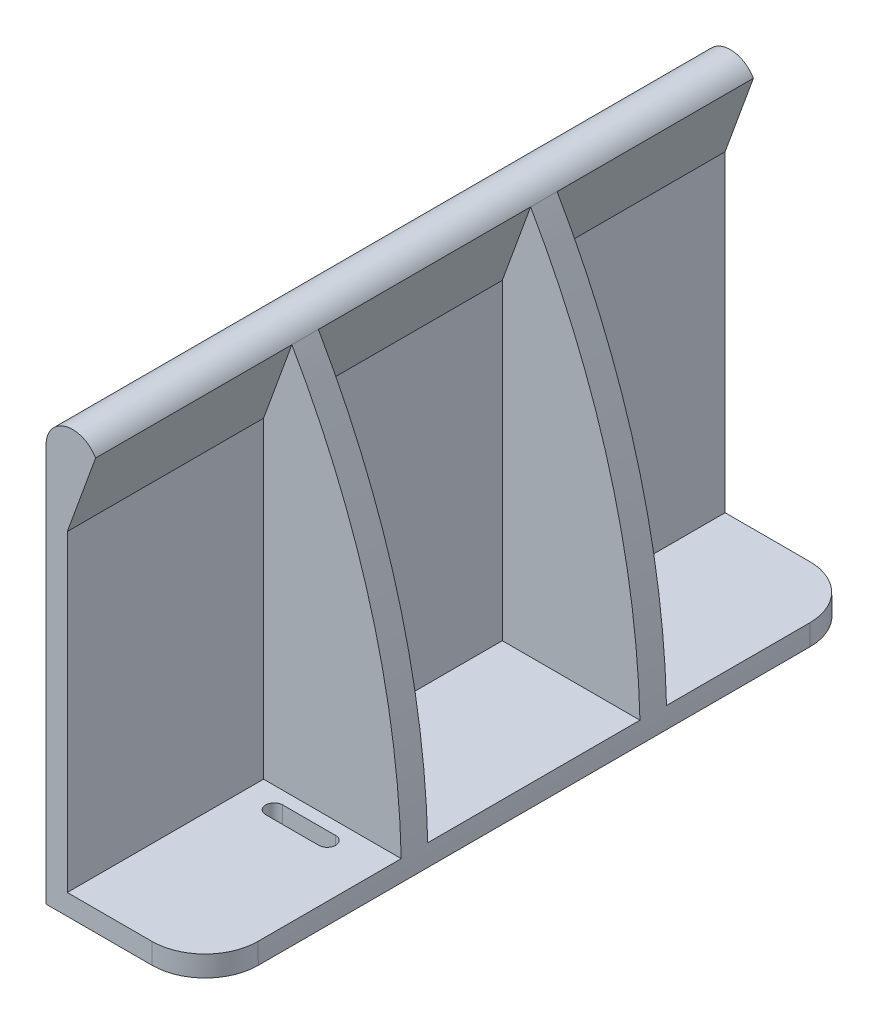
from build123d import *

# Parameters (mm, degrees)
SALIENTE_EXTRUIR1_DEPTH = 62
CORTAR_EXTRUIR1_DEPTH   = 20
CORTAR_EXTRUIR2_START   = 25
CORTAR_EXTRUIR2_DEPTH   = 124
CORTAR_EXTRUIR3_DEPTH   = 3.901378
REDONDEO1_R             = 10


with BuildPart() as part:
    # Croquis1 → Saliente-Extruir1 (new body, symmetric)
    with BuildSketch(Plane.XY):
        with BuildLine():
            Line((0, 0), (0, 75))
            ThreePointArc((0, 75), (3.711686747, 79.831174698), (9.336099585, 77.489626556))
            ThreePointArc((9.336099585, 77.489626556), (24.745312475, 40.098749993), (30, 0))
            Line((30, 0), (0, 0))
        make_face()
    extrude(amount=SALIENTE_EXTRUIR1_DEPTH, both=True)

    # Croquis3 → Cortar-Extruir1 (cut, symmetric)
    with BuildSketch(Plane.XY):
        Polygon((9.336099585, 77.489626556), (4, 62.828813438), (4, 4), (29.948585885, 4), (32.228439928, 77.489626556), align=None)
    extrude(amount=CORTAR_EXTRUIR1_DEPTH, both=True, mode=Mode.SUBTRACT)

    # Croquis4 → Cortar-Extruir2 (cut)
    with BuildSketch(Plane.XY.offset(CORTAR_EXTRUIR2_START)):
        Polygon((9.336099585, 77.489626556), (4, 62.828813438), (4, 3.901378225), (34.928853612, 3.901378225), (21.567933324, 77.489626556), align=None)
    cortar_extruir2 = extrude(amount=CORTAR_EXTRUIR2_DEPTH, mode=Mode.SUBTRACT)

    # Simetría1: Cortar-Extruir2 across plane
    add(cortar_extruir2.mirror(Plane.XY), mode=Mode.SUBTRACT)

    # Croquis5 → Cortar-Extruir3 (cut)
    with BuildSketch(Plane.XZ):
        with BuildLine():
            Line((10, 30.6), (20, 30.6))
            ThreePointArc((20, 30.6), (21.6, 29), (20, 27.4))
            Line((20, 27.4), (10, 27.4))
            ThreePointArc((10, 27.4), (8.4, 29), (10, 30.6))
        make_face()
        with BuildLine():
            Line((10, -30.6), (20, -30.6))
            ThreePointArc((20, -30.6), (21.6, -29), (20, -27.4))
            Line((20, -27.4), (10, -27.4))
            ThreePointArc((10, -27.4), (8.4, -29), (10, -30.6))
        make_face()
    extrude(amount=-CORTAR_EXTRUIR3_DEPTH, mode=Mode.SUBTRACT)

    # Redondeo1
    redondeo1_edges = [part.edges().sort_by_distance(p)[0] for p in [
        (29.987772095, 1.950842396, -62),
        (29.987772095, 1.950842396, 62),
    ]]
    fillet(redondeo1_edges, radius=REDONDEO1_R)


solid = part.part
